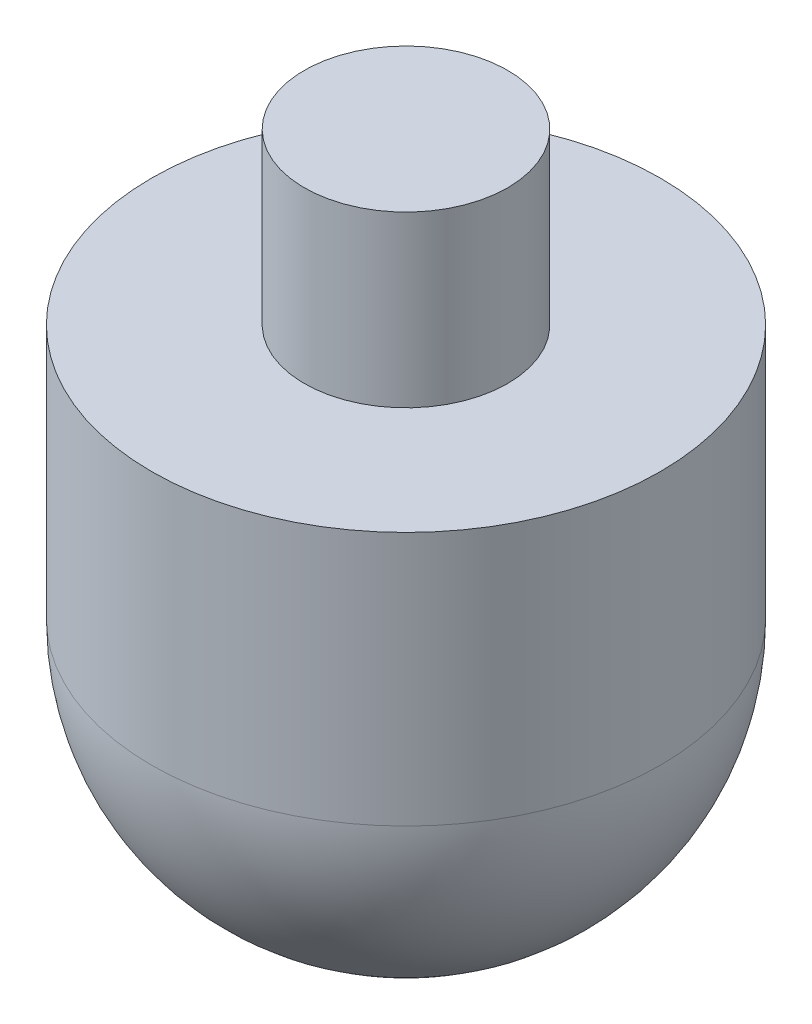
from build123d import *

# Parameters (mm, degrees)
FILLET7_R = 15


with BuildPart() as part:
    # Sketch1 → Revolve2 (revolve)
    with BuildSketch(Plane.XY):
        Polygon((0, 0), (6, 0), (6, -10), (15, -10), (15, -40), (0, -40), align=None)
    revolve(axis=Axis((0, -40, 0), (0, 1, 0)))

    # Fillet7
    fillet7_edges = [part.edges().sort_by_distance(p)[0] for p in [
        (-15, -40, 0),
    ]]
    fillet(fillet7_edges, radius=FILLET7_R)


solid = part.part
